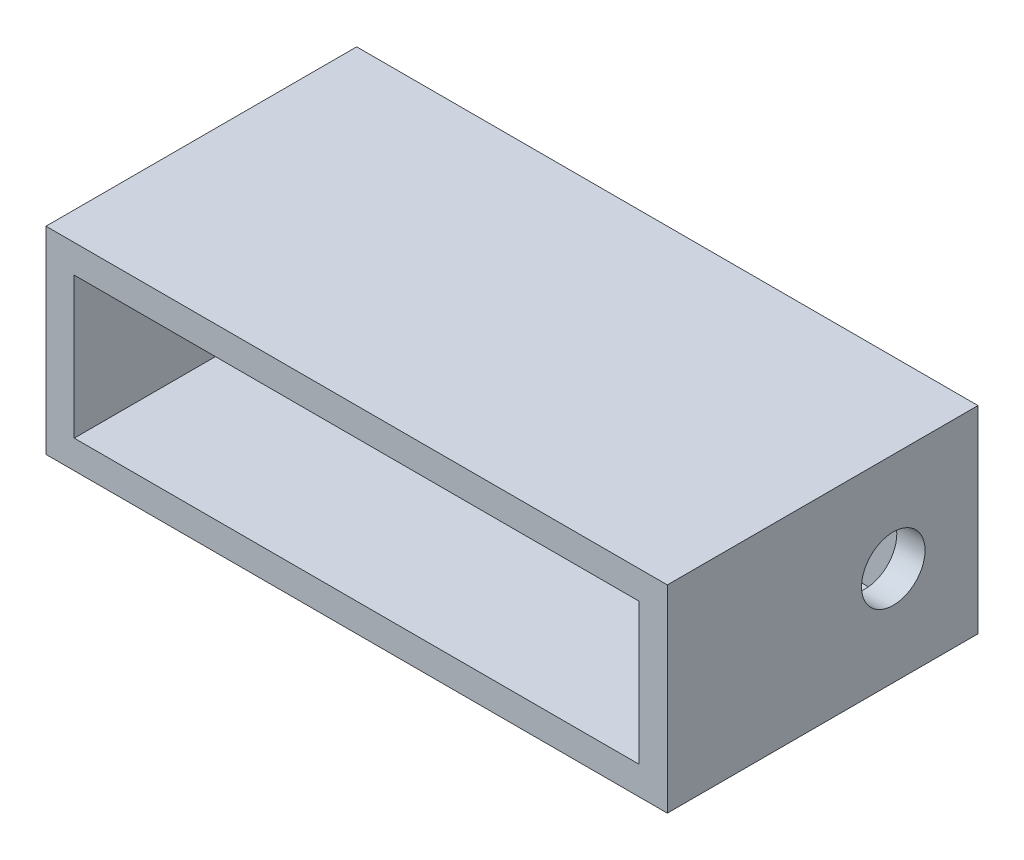
from build123d import *

# Parameters (mm, degrees)
ESBO_O1_W                = 44
ESBO_O1_H                = 14
RESSALTO_EXTRUS_O1_DEPTH = 22
ESBO_O2_W                = 40
ESBO_O2_H                = 10
CORTE_EXTRUS_O1_DEPTH    = 19
ESBO_O3_R                = 2.25
CORTE_EXTRUS_O2_DEPTH    = 5


with BuildPart() as part:
    # Esboço1 → Ressalto-extrusão1 (new body)
    with BuildSketch(Plane.XY):
        Rectangle(ESBO_O1_W, ESBO_O1_H)
    extrude(amount=RESSALTO_EXTRUS_O1_DEPTH)

    # Esboço2 → Corte-extrusão1 (cut)
    with BuildSketch(Plane.XY.offset(22)):
        Rectangle(ESBO_O2_W, ESBO_O2_H)
    extrude(amount=-CORTE_EXTRUS_O1_DEPTH, mode=Mode.SUBTRACT)

    # Esboço3 → Corte-extrusão2 (cut)
    with BuildSketch(Plane(origin=(22, 0, 0), x_dir=(0, 0, -1), z_dir=(1, 0, 0))):
        with Locations((-6, 0)):
            Circle(ESBO_O3_R)
    extrude(amount=-CORTE_EXTRUS_O2_DEPTH, mode=Mode.SUBTRACT)


solid = part.part
